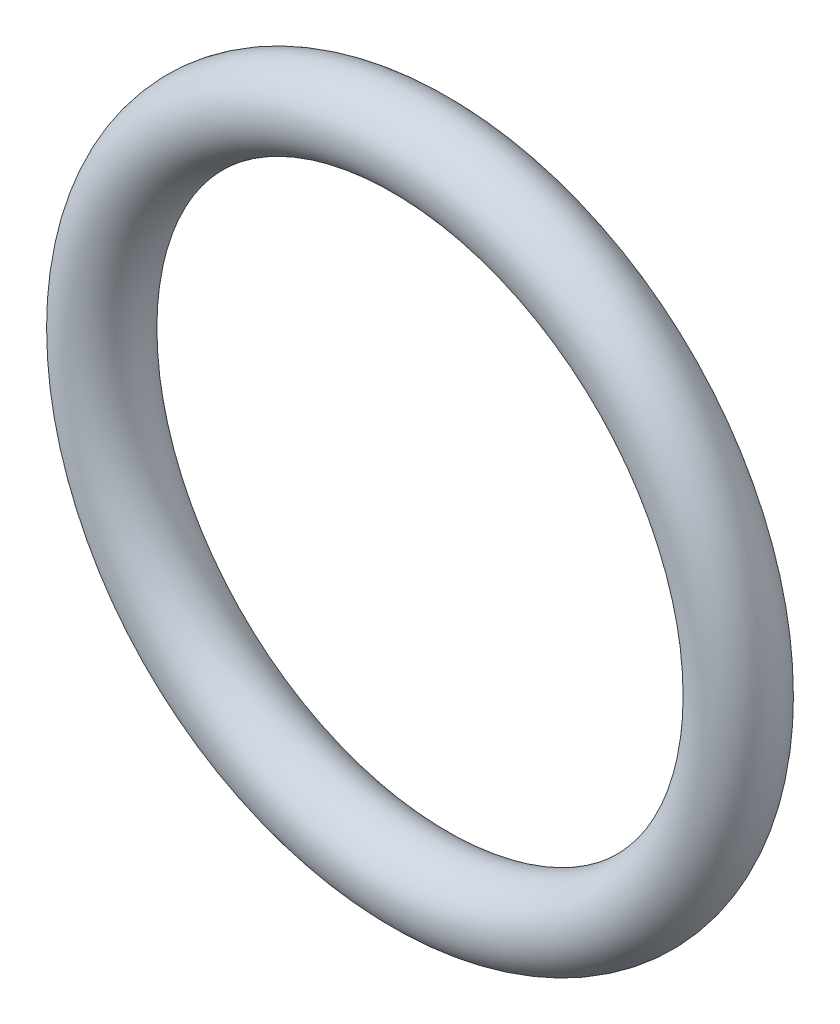
from build123d import *

# Parameters (mm, degrees)
SKETCH1_R = 1.3081


with BuildPart() as part:
    # Sketch1 → Revolve1 (revolve)
    with BuildSketch(Plane(origin=(0, 0, 0), x_dir=(0, -1, 0), z_dir=(1, 0, 0))):
        with Locations((10.668, 0)):
            Circle(SKETCH1_R)
    revolve(axis=Axis((0, 0, 1.3081), (0, 0, -1)))


solid = part.part
